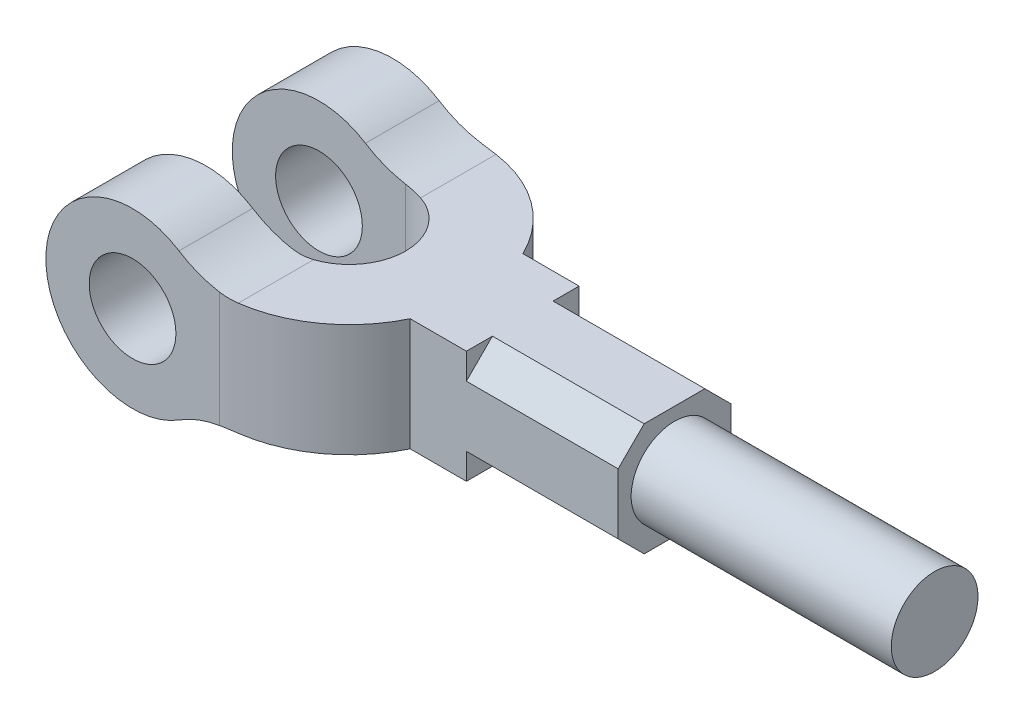
from build123d import *

# Parameters (mm, degrees)
SKETCH1_W           = 115
SKETCH1_H           = 60
BOSS_EXTRUDE1_DEPTH = 40
CUT_EXTRUDE1_DEPTH  = 40
CUT_EXTRUDE3_DEPTH  = 98
SKETCH3_4_R         = 10
CUT_EXTRUDE4_DEPTH  = 98
SKETCH4_R           = 10
BOSS_EXTRUDE2_DEPTH = 60
CUT_EXTRUDE5_START  = -35
SKETCH4_3_R         = 10
CUT_EXTRUDE5_DEPTH  = 35


with BuildPart() as part:
    # Sketch1 → Boss-Extrude1 (new body)
    with BuildSketch(Plane(origin=(0, 0, 0), x_dir=(1, 0, 0), z_dir=(0, 1, 0))):
        Rectangle(SKETCH1_W, SKETCH1_H)
    extrude(amount=BOSS_EXTRUDE1_DEPTH)

    # Sketch2 → Cut-Extrude1 (cut)
    with BuildSketch(Plane(origin=(0, 40, 0), x_dir=(1, 0, 0), z_dir=(0, 1, 0))):
        with BuildLine():
            Line((-17.5, 13), (-57.5, 13))
            Line((-57.5, 13), (-57.5, -13))
            Line((-57.5, -13), (-17.5, -13))
            ThreePointArc((-17.5, -13), (-4.5, 0), (-17.5, 13))
        make_face()
        with BuildLine():
            Line((57.5, 30), (-17.5, 30))
            ThreePointArc((-17.5, 30), (-1.531280577, 25.396850198), (9.537011669, 13))
            Line((9.537011669, 13), (57.5, 13))
            Line((57.5, 13), (57.5, 30))
        make_face()
        with BuildLine():
            ThreePointArc((9.537011669, -13), (-1.531280577, -25.396850198), (-17.5, -30))
            Line((-17.5, -30), (57.5, -30))
            Line((57.5, -30), (57.5, -13))
            Line((57.5, -13), (9.537011669, -13))
        make_face()
    extrude(amount=-CUT_EXTRUDE1_DEPTH, mode=Mode.SUBTRACT)

    # Sketch3 → Cut-Extrude3 (cut)
    with BuildSketch(Plane.XY.offset(30)):
        with BuildLine():
            Line((57.5, 7), (-13.396058414, 7))
            ThreePointArc((-13.396058414, 7), (-20.368225301, 6.008100485), (-26.787137073, 3.111111111))
            ThreePointArc((-26.787137073, 3.111111111), (-31.922266567, 0.79351959), (-37.50000016, 0))
            Line((-37.50000016, 0), (57.5, 0))
            Line((57.5, 0), (57.5, 7))
        make_face()
        with BuildLine():
            Line((-13.396058414, 33), (57.5, 33))
            Line((57.5, 33), (57.5, 40))
            Line((57.5, 40), (-37.5, 40))
            ThreePointArc((-37.5, 40), (-31.92226649, 39.206480388), (-26.787137073, 36.888888889))
            ThreePointArc((-26.787137073, 36.888888889), (-20.368225301, 33.991899515), (-13.396058414, 33))
        make_face()
        with BuildLine():
            Line((-57.5, 0), (-37.50000016, 0))
            ThreePointArc((-37.50000016, 0), (-51.642135645, 5.857864398), (-57.5, 19.999999901))
            Line((-57.5, 19.999999901), (-57.5, 0))
        make_face()
        with BuildLine():
            Line((-57.5, 40), (-57.5, 19.999999901))
            ThreePointArc((-57.5, 19.999999901), (-51.642135659, 34.142135589), (-37.5, 40))
            Line((-37.5, 40), (-57.5, 40))
        make_face()
    extrude(amount=-CUT_EXTRUDE3_DEPTH, mode=Mode.SUBTRACT)

    # Sketch3_4 → Cut-Extrude4 (cut)
    with BuildSketch(Plane.XY.offset(30)):
        with Locations((-37.5, 20)):
            Circle(SKETCH3_4_R)
    extrude(amount=-CUT_EXTRUDE4_DEPTH, mode=Mode.SUBTRACT)

    # Sketch4 → Boss-Extrude2 (add)
    with BuildSketch(Plane(origin=(57.5, 0, 0), x_dir=(0, 0, -1), z_dir=(1, 0, 0))):
        with Locations((0, 20)):
            Circle(SKETCH4_R)
    extrude(amount=BOSS_EXTRUDE2_DEPTH)

    # Sketch4_3 → Cut-Extrude5 (cut)
    with BuildSketch(Plane(origin=(57.5, 0, 0), x_dir=(0, 0, -1), z_dir=(1, 0, 0)).offset(CUT_EXTRUDE5_START)):
        with Locations((0, 20)):
            Circle(SKETCH4_3_R)
        Polygon((-13, 33), (-13, 27), (-7, 33), align=None)
        Polygon((13, 33), (7, 33), (13, 27), align=None)
        Polygon((13, 7), (13, 13), (7, 7), align=None)
        Polygon((-13, 7), (-7, 7), (-13, 13), align=None)
    extrude(amount=CUT_EXTRUDE5_DEPTH, mode=Mode.SUBTRACT)


with BuildPart() as cut_extrude5_piece_1:
    # of the separate pieces the step leaves, piece 1, a body of its own (cut_extrude5_pieces)
    add(part.part.solids().sort_by_distance((-26.787137073, 3.111111111, -30))[0])


with BuildPart() as cut_extrude5_piece_2:
    # of the separate pieces the step leaves, piece 2, a body of its own (cut_extrude5_pieces)
    add(part.part.solids().sort_by_distance((117.5, 20, -10))[0])


solid = Compound([cut_extrude5_piece_1.part, cut_extrude5_piece_2.part])
